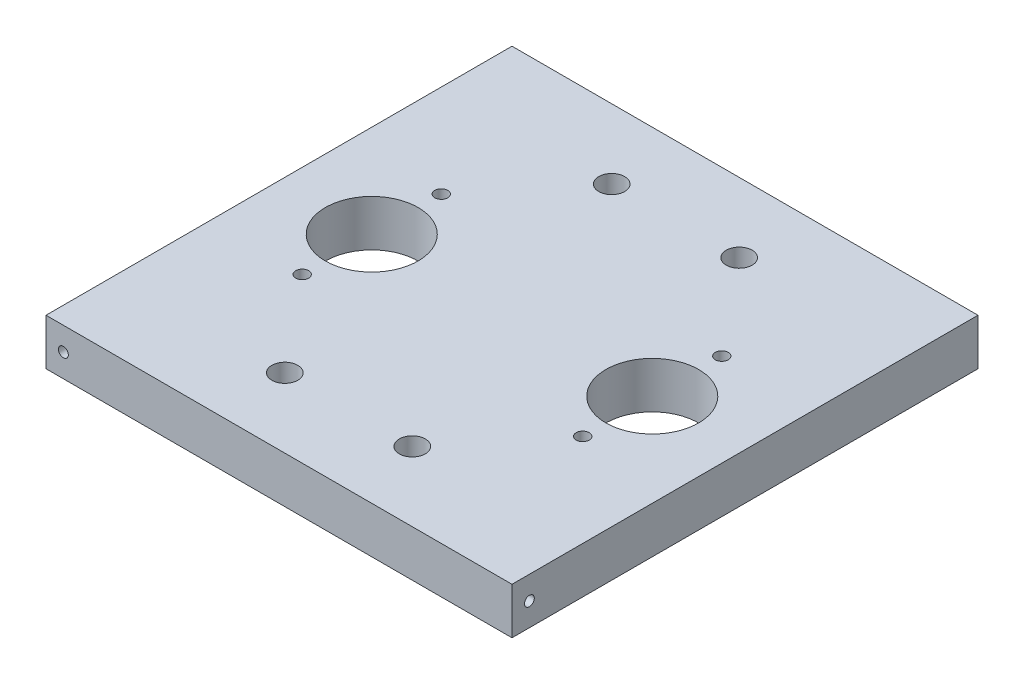
from build123d import *

# Parameters (mm, degrees)
SKETCH1_W                      = 127.635
SKETCH1_H                      = 127.635
MAIN_PLATE_DEPTH               = 12.7
SKETCH2_R                      = 3.556
U_BOLT_HOLE_DEPTH              = 12.7
U_BOLT_PATTERN_COUNT           = 2
U_BOLT_PATTERN_PITCH           = 34.925
U_BOLT_PATTERN_COUNT_DIR2      = 2
U_BOLT_PATTERN_PITCH_DIR2      = 89.535
SKETCH3_R                      = 1.778
RAPTOR_BOLT_HOLE_DEPTH         = 12.7
RAPTOR_BOLT_PATTERN_COUNT      = 2
RAPTOR_BOLT_PATTERN_PITCH      = 38.1
RAPTOR_BOLT_PATTERN_COUNT_DIR2 = 2
RAPTOR_BOLT_PATTERN_PITCH_DIR2 = 76.835
SKETCH4_R                      = 12.7
CO2_CYLINDER_HOLE_DEPTH        = 12.7
CO2_PATTERN_COUNT              = 2
CO2_PATTERN_PITCH              = 76.835
SKETCH5_R                      = 1.35255
FRAME_ATTACHMENT_HOLE_1_DEPTH  = 12.7
SKETCH6_R                      = 1.35255
FRAME_ATTACHMENT_HOLE_2_DEPTH  = 12.7
SKETCH7_R                      = 1.35255
FRAME_ATTACHMENT_HOLE_3_DEPTH  = 12.7
SKETCH8_R                      = 1.35255
FRAME_ATTACHMENT_HOLE_4_DEPTH  = 12.7


with BuildPart() as part:
    # Sketch1 → Main Plate (new body)
    with BuildSketch(Plane(origin=(0, 0, 0), x_dir=(1, 0, 0), z_dir=(0, 1, 0))):
        with Locations((63.8175, 63.8175)):
            Rectangle(SKETCH1_W, SKETCH1_H)
    extrude(amount=MAIN_PLATE_DEPTH)

    # Sketch2 → U-Bolt Hole (cut)
    with BuildSketch(Plane(origin=(0, 12.7, 0), x_dir=(1, 0, 0), z_dir=(0, 1, 0))):
        with Locations((46.355, 108.585)):
            Circle(SKETCH2_R)
    u_bolt_hole = extrude(amount=-U_BOLT_HOLE_DEPTH, mode=Mode.SUBTRACT)

    # U-Bolt Pattern: U-Bolt Hole 2 × 2
    with Locations(*[(i * U_BOLT_PATTERN_PITCH, 0, j * U_BOLT_PATTERN_PITCH_DIR2) for i in range(U_BOLT_PATTERN_COUNT) for j in range(U_BOLT_PATTERN_COUNT_DIR2) if (i, j) != (0, 0)]):
        add(u_bolt_hole, mode=Mode.SUBTRACT)

    # Sketch3 → Raptor Bolt Hole (cut)
    with BuildSketch(Plane(origin=(0, 12.7, 0), x_dir=(1, 0, 0), z_dir=(0, 1, 0))):
        with Locations((25.4, 44.7675)):
            Circle(SKETCH3_R)
    raptor_bolt_hole = extrude(amount=-RAPTOR_BOLT_HOLE_DEPTH, mode=Mode.SUBTRACT)

    # Raptor Bolt Pattern: Raptor Bolt Hole 2 × 2
    with Locations(*[(j * RAPTOR_BOLT_PATTERN_PITCH_DIR2, 0, -i * RAPTOR_BOLT_PATTERN_PITCH) for i in range(RAPTOR_BOLT_PATTERN_COUNT) for j in range(RAPTOR_BOLT_PATTERN_COUNT_DIR2) if (i, j) != (0, 0)]):
        add(raptor_bolt_hole, mode=Mode.SUBTRACT)

    # Sketch4 → Co2 Cylinder Hole (cut)
    with BuildSketch(Plane(origin=(0, 12.7, 0), x_dir=(1, 0, 0), z_dir=(0, 1, 0))):
        with Locations((25.4, 63.8175)):
            Circle(SKETCH4_R)
    co2_cylinder_hole = extrude(amount=-CO2_CYLINDER_HOLE_DEPTH, mode=Mode.SUBTRACT)

    # Co2 Pattern: Co2 Cylinder Hole ×2
    with Locations(*[(i * CO2_PATTERN_PITCH, 0, 0) for i in range(1, CO2_PATTERN_COUNT)]):
        add(co2_cylinder_hole, mode=Mode.SUBTRACT)

    # Sketch5 → Frame attachment hole 1 (cut)
    with BuildSketch(Plane.XY):
        with Locations((4.7625, 6.35)):
            Circle(SKETCH5_R)
    extrude(amount=-FRAME_ATTACHMENT_HOLE_1_DEPTH, mode=Mode.SUBTRACT)

    # Sketch6 → Frame attachment hole 2 (cut)
    with BuildSketch(Plane.ZY):
        with Locations((-122.8725, 6.35)):
            Circle(SKETCH6_R)
    extrude(amount=-FRAME_ATTACHMENT_HOLE_2_DEPTH, mode=Mode.SUBTRACT)

    # Sketch7 → Frame attachment hole 3 (cut)
    with BuildSketch(Plane(origin=(0, 0, -127.635), x_dir=(-1, 0, 0), z_dir=(0, 0, -1))):
        with Locations((-122.8725, 6.35)):
            Circle(SKETCH7_R)
    extrude(amount=-FRAME_ATTACHMENT_HOLE_3_DEPTH, mode=Mode.SUBTRACT)

    # Sketch8 → Frame attachment hole 4 (cut)
    with BuildSketch(Plane(origin=(127.635, 0, 0), x_dir=(0, 0, -1), z_dir=(1, 0, 0))):
        with Locations((4.7625, 6.35)):
            Circle(SKETCH8_R)
    extrude(amount=-FRAME_ATTACHMENT_HOLE_4_DEPTH, mode=Mode.SUBTRACT)


solid = part.part
